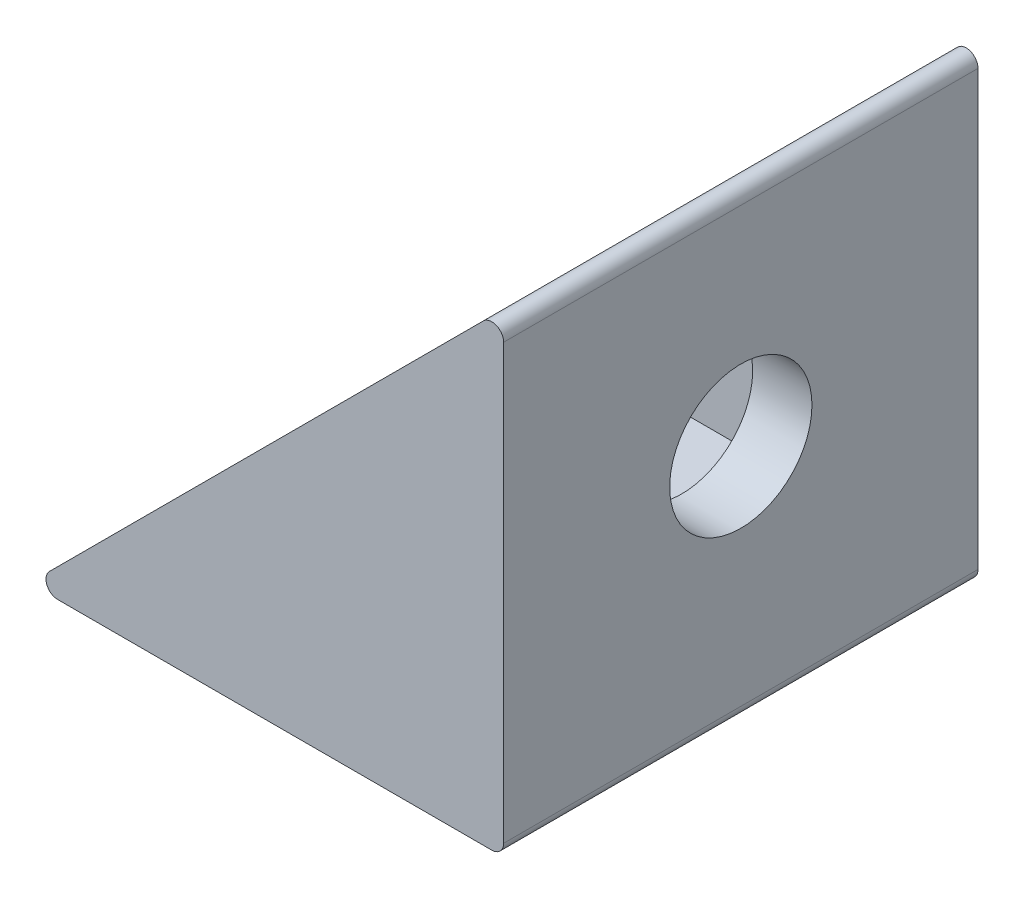
from build123d import *

# Parameters (mm, degrees)
SKETCH1_W               = 20
SKETCH1_H               = 20
BOSS_EXTRUDE1_DEPTH     = 20
CUT_EXTRUDE1_DEPTH      = 1
CUT_EXTRUDE1_DEPTH_BACK = 21
SKETCH3_R               = 3
CUT_EXTRUDE2_DEPTH      = 21
SKETCH4_R               = 3
CUT_EXTRUDE3_DEPTH      = 21
SKETCH5_W               = 15
SKETCH5_H               = 15
CUT_EXTRUDE5_DEPTH      = 17.5
FILLET1_R               = 0.5


with BuildPart() as part:
    # Sketch1 → Boss-Extrude1 (new body)
    with BuildSketch(Plane(origin=(0, 0, 0), x_dir=(1, 0, 0), z_dir=(0, 1, 0))):
        Rectangle(SKETCH1_W, SKETCH1_H)
    extrude(amount=BOSS_EXTRUDE1_DEPTH)

    # Sketch2 → Cut-Extrude1 (cut, two sides)
    with BuildSketch(Plane.XY.offset(10)) as cut_extrude1_sk:
        Polygon((-10, 0), (10, 20), (-10, 20), align=None)
    extrude(amount=CUT_EXTRUDE1_DEPTH, mode=Mode.SUBTRACT)
    extrude(cut_extrude1_sk.sketch, amount=-CUT_EXTRUDE1_DEPTH_BACK, mode=Mode.SUBTRACT)

    # Sketch3 → Cut-Extrude2 (cut, through all)
    with BuildSketch(Plane(origin=(10, 0, 0), x_dir=(0, 0, -1), z_dir=(1, 0, 0))):
        with Locations((0, 10)):
            Circle(SKETCH3_R)
    extrude(amount=-CUT_EXTRUDE2_DEPTH, mode=Mode.SUBTRACT)

    # Sketch4 → Cut-Extrude3 (cut, through all)
    with BuildSketch(Plane.XZ):
        Circle(SKETCH4_R)
    extrude(amount=-CUT_EXTRUDE3_DEPTH, mode=Mode.SUBTRACT)

    # Sketch5 → Cut-Extrude5 (cut)
    with BuildSketch(Plane(origin=(0, 20, 0), x_dir=(1, 0, 0), z_dir=(0, 1, 0))):
        Rectangle(SKETCH5_W, SKETCH5_H)
    extrude(amount=-CUT_EXTRUDE5_DEPTH, mode=Mode.SUBTRACT)

    # Fillet1
    fillet1_edges = [part.edges().sort_by_distance(p)[0] for p in [
        (10, 20, 0),
        (-10, 0, 0),
        (10, 0, 0),
    ]]
    fillet(fillet1_edges, radius=FILLET1_R)


solid = part.part
